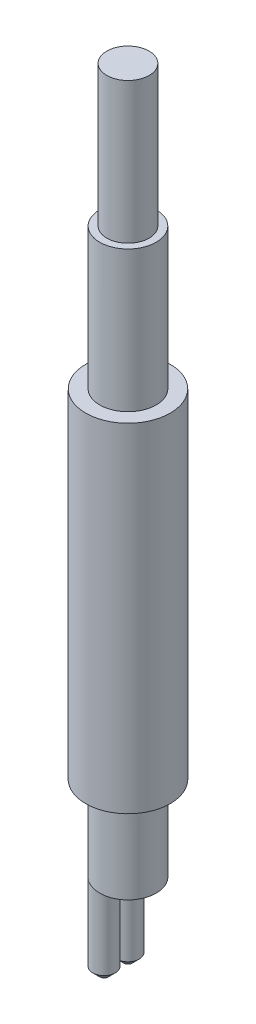
from build123d import *

# Parameters (mm, degrees)
SKIZZE1_R                            = 1
SKIZZE1_R_2                          = 0.75
AUFSATZ_LINEAR_AUSTRAGEN1_DEPTH      = 20
SKIZZE2_R                            = 0.75
AUFSATZ_LINEAR_AUSTRAGEN2_DEPTH      = 5
AUFSATZ_LINEAR_AUSTRAGEN2_DEPTH_BACK = 20
SKIZZE3_R                            = 1.5
SKIZZE3_R_2                          = 1
LINEAR_AUSTRAGEN_D_NN1_DEPTH         = 12
SKIZZE5_R                            = 0.4
AUFSATZ_LINEAR_AUSTRAGEN3_DEPTH      = 3
FASE1_SIZE                           = 0.25


with BuildPart() as part:
    # Skizze1 → Aufsatz-Linear austragen1 (new body)
    with BuildSketch(Plane(origin=(0, 0, 0), x_dir=(1, 0, 0), z_dir=(0, 1, 0))):
        Circle(SKIZZE1_R)
        Circle(SKIZZE1_R_2, mode=Mode.SUBTRACT)
    extrude(amount=AUFSATZ_LINEAR_AUSTRAGEN1_DEPTH)

    # Skizze5 → Aufsatz-Linear austragen3 (add)
    with BuildSketch(Plane.XZ):
        with Locations((-0.424264069, -0.424264069)):
            Circle(SKIZZE5_R)
        with Locations((-0.424264069, 0.424264069)):
            Circle(SKIZZE5_R)
    extrude(amount=AUFSATZ_LINEAR_AUSTRAGEN3_DEPTH)

    # Fase1
    fase1_edges = [part.edges().sort_by_distance(p)[0] for p in [
        (-0.824264069, -3, -0.424264069),
        (-0.824264069, -3, 0.424264069),
    ]]
    chamfer(fase1_edges, length=FASE1_SIZE)


with BuildPart() as body_2:
    # Skizze2 → Aufsatz-Linear austragen2 (new body, two sides)
    with BuildSketch(Plane(origin=(0, 20, 0), x_dir=(1, 0, 0), z_dir=(0, 1, 0))) as aufsatz_linear_austragen2_sk:
        Circle(SKIZZE2_R)
    extrude(amount=AUFSATZ_LINEAR_AUSTRAGEN2_DEPTH)
    extrude(aufsatz_linear_austragen2_sk.sketch, amount=-AUFSATZ_LINEAR_AUSTRAGEN2_DEPTH_BACK)


with BuildPart() as body_3:
    # Skizze3 → Linear-Austragen-Dünn1 (new body)
    with BuildSketch(Plane(origin=(0, 3, 0), x_dir=(1, 0, 0), z_dir=(0, 1, 0))):
        Circle(SKIZZE3_R)
        Circle(SKIZZE3_R_2, mode=Mode.SUBTRACT)
    extrude(amount=LINEAR_AUSTRAGEN_D_NN1_DEPTH)


solid = Compound([part.part, body_2.part, body_3.part])
